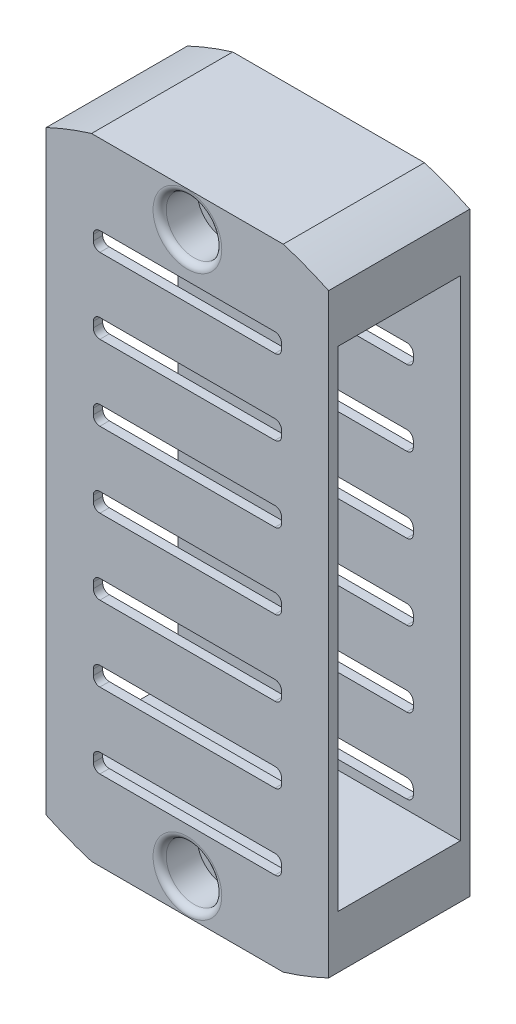
from build123d import *

# Parameters (mm, degrees)
BOSS_EXTRUDE1_DEPTH     = 13
BOSS_EXTRUDE1_2_DEPTH   = 13
BOSS_EXTRUDE2_DEPTH     = 1
CUT_EXTRUDE1_DEPTH      = 1
CUT_EXTRUDE1_DEPTH_BACK = 15
SKETCH5_R               = 2.95
CUT_EXTRUDE2_DEPTH      = 4
SKETCH6_R               = 1.7
CUT_EXTRUDE3_DEPTH      = 15
SKETCH7_R               = 2.95
CUT_EXTRUDE4_DEPTH      = 5
FILLET1_R               = 0.7


with BuildPart() as part:
    # Sketch1 → Boss-Extrude1 (new body)
    with BuildSketch(Plane.XY):
        with BuildLine():
            Line((20.312335657, 66.943000793), (-0.059999997, 66.943000793))
            ThreePointArc((-0.059999997, 66.943000793), (-2.501129835, 66.102927517), (-4.873699875, 65.085209777))
            Line((-4.873699875, 65.085209777), (-4.873699875, 59.450000396))
            Line((-4.873699875, 59.450000396), (25.126300125, 59.450000396))
            Line((25.126300125, 59.450000396), (25.126300125, 65.073261004))
            ThreePointArc((25.126300125, 65.073261004), (22.753848848, 66.097036745), (20.312335657, 66.943000793))
        make_face()
    extrude(amount=BOSS_EXTRUDE1_DEPTH)



with BuildPart() as body_2:
    # Sketch1 → Boss-Extrude1 2 (new body)
    with BuildSketch(Plane.XY):
        with BuildLine():
            Line((-4.873699875, 7.450000396), (25.126300125, 7.450000396))
            Line((25.126300125, 7.450000396), (25.126300125, 1.826739788))
            ThreePointArc((25.126300125, 1.826739788), (22.753848848, 0.802964047), (20.312335657, -0.043000001))
            Line((20.312335657, -0.043000001), (-0.059999997, -0.043000001))
            ThreePointArc((-0.059999997, -0.043000001), (-2.501129835, 0.797073275), (-4.873699875, 1.814791015))
            Line((-4.873699875, 1.814791015), (-4.873699875, 7.450000396))
        make_face()
    extrude(amount=BOSS_EXTRUDE1_2_DEPTH)


with BuildPart() as part_1:
    add(part.part)

    add(body_2.part)  # Boss-Extrude2 merges body 2
    # Sketch2 → Boss-Extrude2 (add)
    with BuildSketch(Plane.XY.offset(13)):
        with BuildLine():
            Line((-4.873699875, 7.450000396), (-4.873699875, 1.814791015))
            ThreePointArc((-4.873699875, 1.814791015), (-2.501129835, 0.797073275), (-0.059999997, -0.043000001))
            Line((-0.059999997, -0.043000001), (20.312335657, -0.043000001))
            ThreePointArc((20.312335657, -0.043000001), (22.753848848, 0.802964047), (25.126300125, 1.826739788))
            Line((25.126300125, 1.826739788), (25.126300125, 7.450000396))
            Line((25.126300125, 7.450000396), (25.126300125, 59.450000396))
            Line((25.126300125, 59.450000396), (25.126300125, 65.073261004))
            ThreePointArc((25.126300125, 65.073261004), (22.753848848, 66.097036745), (20.312335657, 66.943000793))
            Line((20.312335657, 66.943000793), (-0.059999997, 66.943000793))
            ThreePointArc((-0.059999997, 66.943000793), (-2.501129835, 66.102927517), (-4.873699875, 65.085209777))
            Line((-4.873699875, 65.085209777), (-4.873699875, 59.450000396))
            Line((-4.873699875, 59.450000396), (-4.873699875, 7.450000396))
        make_face()
    boss_extrude2 = extrude(amount=BOSS_EXTRUDE2_DEPTH)

    # Mirror1: Boss-Extrude2 across plane
    add(boss_extrude2.mirror(Plane(origin=(0, 0, 6.5), x_dir=(1, 0, 0), z_dir=(0, 0, -1))))

    # Sketch3 → Cut-Extrude1 (cut, two sides)
    with BuildSketch(Plane.XY.offset(14)) as cut_extrude1_sk:
        with BuildLine():
            Line((19.426300125, 40.450000396), (0.826300125, 40.450000396))
            ThreePointArc((0.826300125, 40.450000396), (0.331325379, 40.655025649), (0.126300125, 41.150000396))
            Line((0.126300125, 41.150000396), (0.126300125, 41.750000396))
            ThreePointArc((0.126300125, 41.750000396), (0.331325379, 42.244975143), (0.826300125, 42.450000396))
            Line((0.826300125, 42.450000396), (19.426300125, 42.450000396))
            ThreePointArc((19.426300125, 42.450000396), (19.921274872, 42.244975143), (20.126300125, 41.750000396))
            Line((20.126300125, 41.750000396), (20.126300125, 41.150000396))
            ThreePointArc((20.126300125, 41.150000396), (19.921274872, 40.655025649), (19.426300125, 40.450000396))
        make_face()
        with BuildLine():
            Line((19.426300125, 32.450000396), (0.826300125, 32.450000396))
            ThreePointArc((0.826300125, 32.450000396), (0.331325379, 32.655025649), (0.126300125, 33.150000396))
            Line((0.126300125, 33.150000396), (0.126300125, 33.750000396))
            ThreePointArc((0.126300125, 33.750000396), (0.331325379, 34.244975143), (0.826300125, 34.450000396))
            Line((0.826300125, 34.450000396), (19.426300125, 34.450000396))
            ThreePointArc((19.426300125, 34.450000396), (19.921274872, 34.244975143), (20.126300125, 33.750000396))
            Line((20.126300125, 33.750000396), (20.126300125, 33.150000396))
            ThreePointArc((20.126300125, 33.150000396), (19.921274872, 32.655025649), (19.426300125, 32.450000396))
        make_face()
        with BuildLine():
            Line((19.426300125, 48.450000396), (0.826300125, 48.450000396))
            ThreePointArc((0.826300125, 48.450000396), (0.331325379, 48.655025649), (0.126300125, 49.150000396))
            Line((0.126300125, 49.150000396), (0.126300125, 49.750000396))
            ThreePointArc((0.126300125, 49.750000396), (0.331325379, 50.244975143), (0.826300125, 50.450000396))
            Line((0.826300125, 50.450000396), (19.426300125, 50.450000396))
            ThreePointArc((19.426300125, 50.450000396), (19.921274872, 50.244975143), (20.126300125, 49.750000396))
            Line((20.126300125, 49.750000396), (20.126300125, 49.150000396))
            ThreePointArc((20.126300125, 49.150000396), (19.921274872, 48.655025649), (19.426300125, 48.450000396))
        make_face()
        with BuildLine():
            Line((19.426300125, 56.450000396), (0.826300125, 56.450000396))
            ThreePointArc((0.826300125, 56.450000396), (0.331325379, 56.655025649), (0.126300125, 57.150000396))
            Line((0.126300125, 57.150000396), (0.126300125, 57.750000396))
            ThreePointArc((0.126300125, 57.750000396), (0.331325379, 58.244975143), (0.826300125, 58.450000396))
            Line((0.826300125, 58.450000396), (19.426300125, 58.450000396))
            ThreePointArc((19.426300125, 58.450000396), (19.921274872, 58.244975143), (20.126300125, 57.750000396))
            Line((20.126300125, 57.750000396), (20.126300125, 57.150000396))
            ThreePointArc((20.126300125, 57.150000396), (19.921274872, 56.655025649), (19.426300125, 56.450000396))
        make_face()
        with BuildLine():
            Line((19.426300125, 24.450000396), (0.826300125, 24.450000396))
            ThreePointArc((0.826300125, 24.450000396), (0.331325379, 24.655025649), (0.126300125, 25.150000396))
            Line((0.126300125, 25.150000396), (0.126300125, 25.750000396))
            ThreePointArc((0.126300125, 25.750000396), (0.331325379, 26.244975143), (0.826300125, 26.450000396))
            Line((0.826300125, 26.450000396), (19.426300125, 26.450000396))
            ThreePointArc((19.426300125, 26.450000396), (19.921274872, 26.244975143), (20.126300125, 25.750000396))
            Line((20.126300125, 25.750000396), (20.126300125, 25.150000396))
            ThreePointArc((20.126300125, 25.150000396), (19.921274872, 24.655025649), (19.426300125, 24.450000396))
        make_face()
        with BuildLine():
            Line((19.426300125, 16.450000396), (0.826300125, 16.450000396))
            ThreePointArc((0.826300125, 16.450000396), (0.331325379, 16.655025649), (0.126300125, 17.150000396))
            Line((0.126300125, 17.150000396), (0.126300125, 17.750000396))
            ThreePointArc((0.126300125, 17.750000396), (0.331325379, 18.244975143), (0.826300125, 18.450000396))
            Line((0.826300125, 18.450000396), (19.426300125, 18.450000396))
            ThreePointArc((19.426300125, 18.450000396), (19.921274872, 18.244975143), (20.126300125, 17.750000396))
            Line((20.126300125, 17.750000396), (20.126300125, 17.150000396))
            ThreePointArc((20.126300125, 17.150000396), (19.921274872, 16.655025649), (19.426300125, 16.450000396))
        make_face()
        with BuildLine():
            Line((19.426300125, 8.450000396), (0.826300125, 8.450000396))
            ThreePointArc((0.826300125, 8.450000396), (0.331325379, 8.655025649), (0.126300125, 9.150000396))
            Line((0.126300125, 9.150000396), (0.126300125, 9.750000396))
            ThreePointArc((0.126300125, 9.750000396), (0.331325379, 10.244975143), (0.826300125, 10.450000396))
            Line((0.826300125, 10.450000396), (19.426300125, 10.450000396))
            ThreePointArc((19.426300125, 10.450000396), (19.921274872, 10.244975143), (20.126300125, 9.750000396))
            Line((20.126300125, 9.750000396), (20.126300125, 9.150000396))
            ThreePointArc((20.126300125, 9.150000396), (19.921274872, 8.655025649), (19.426300125, 8.450000396))
        make_face()
    extrude(amount=CUT_EXTRUDE1_DEPTH, mode=Mode.SUBTRACT)
    extrude(cut_extrude1_sk.sketch, amount=-CUT_EXTRUDE1_DEPTH_BACK, mode=Mode.SUBTRACT)

    # Sketch5 → Cut-Extrude2 (cut)
    with BuildSketch(Plane.XY.offset(14)):
        with Locations((10.126233978, 3.703500197)):
            Circle(SKETCH5_R)
    cut_extrude2 = extrude(amount=-CUT_EXTRUDE2_DEPTH, mode=Mode.SUBTRACT)

    # Sketch6 → Cut-Extrude3 (cut)
    with BuildSketch(Plane(origin=(0, 0, -1), x_dir=(-1, 0, 0), z_dir=(0, 0, -1))):
        with Locations((-10.126233978, 3.703500197)):
            Circle(SKETCH6_R)
    cut_extrude3 = extrude(amount=-CUT_EXTRUDE3_DEPTH, mode=Mode.SUBTRACT)

    # Sketch7 → Cut-Extrude4 (cut)
    with BuildSketch(Plane(origin=(0, 0, -1), x_dir=(-1, 0, 0), z_dir=(0, 0, -1))):
        with Locations((-10.126233978, 3.703500197)):
            Circle(SKETCH7_R)
    cut_extrude4 = extrude(amount=-CUT_EXTRUDE4_DEPTH, mode=Mode.SUBTRACT)

    # Mirror3: Cut-Extrude2, Cut-Extrude3, Cut-Extrude4 across plane
    add(cut_extrude2.mirror(Plane(origin=(0, 33.450000396, 0), x_dir=(0, 0, 1), z_dir=(0, -1, 0))), mode=Mode.SUBTRACT)
    add(cut_extrude3.mirror(Plane(origin=(0, 33.450000396, 0), x_dir=(0, 0, 1), z_dir=(0, -1, 0))), mode=Mode.SUBTRACT)
    add(cut_extrude4.mirror(Plane(origin=(0, 33.450000396, 0), x_dir=(0, 0, 1), z_dir=(0, -1, 0))), mode=Mode.SUBTRACT)

    # Fillet1
    fillet1_edges = [part_1.edges().sort_by_distance(p)[0] for p in [
        (7.176233978, 3.703500197, 14),
        (13.076233978, 3.703500197, -1),
        (7.176233978, 63.196500595, 14),
        (13.076233978, 63.196500595, -1),
    ]]
    fillet(fillet1_edges, radius=FILLET1_R)


solid = part_1.part
